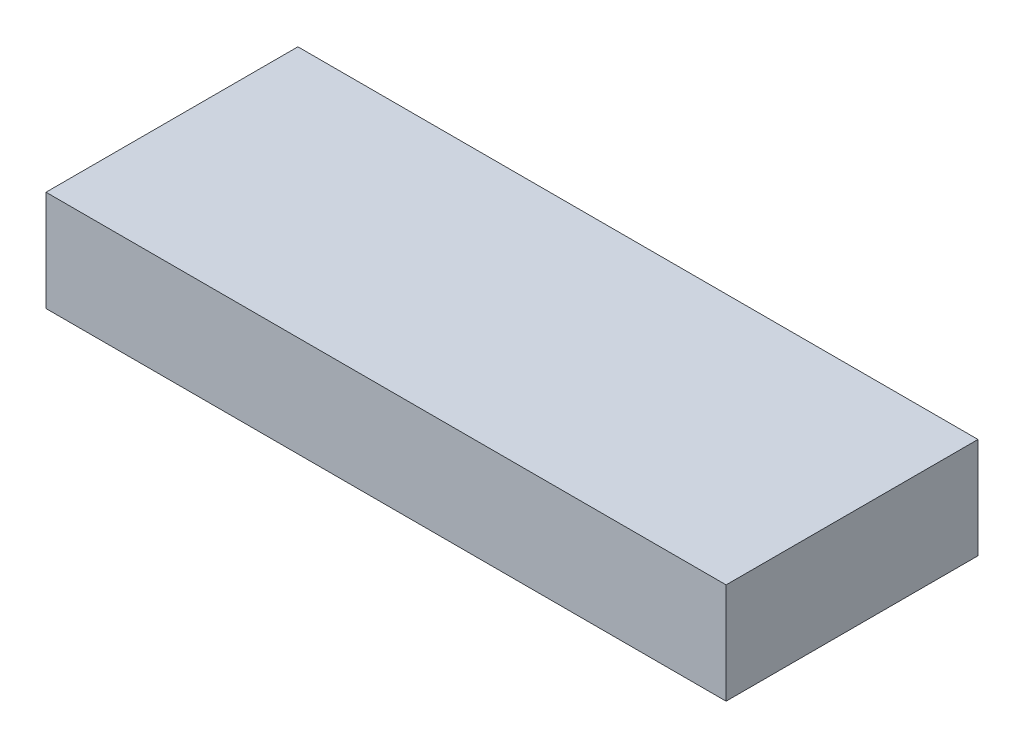
from build123d import *

# Parameters (mm, degrees)
SKETCH1_W           = 68.58
SKETCH1_H           = 25.4
BOSS_EXTRUDE1_DEPTH = 10.16
SKETCH2_R           = 1.126258331
CUT_EXTRUDE1_DEPTH  = 5.08


with BuildPart() as part:
    # Sketch1 → Boss-Extrude1 (new body)
    with BuildSketch(Plane(origin=(0, 0, 0), x_dir=(1, 0, 0), z_dir=(0, 1, 0))):
        with Locations((34.29, 12.7)):
            Rectangle(SKETCH1_W, SKETCH1_H)
    extrude(amount=BOSS_EXTRUDE1_DEPTH)

    # Sketch2 → Cut-Extrude1 (cut)
    with BuildSketch(Plane.ZY):
        with Locations((-12.802546148, 2.016433815)):
            Circle(SKETCH2_R)
    extrude(amount=-CUT_EXTRUDE1_DEPTH, mode=Mode.SUBTRACT)


solid = part.part
